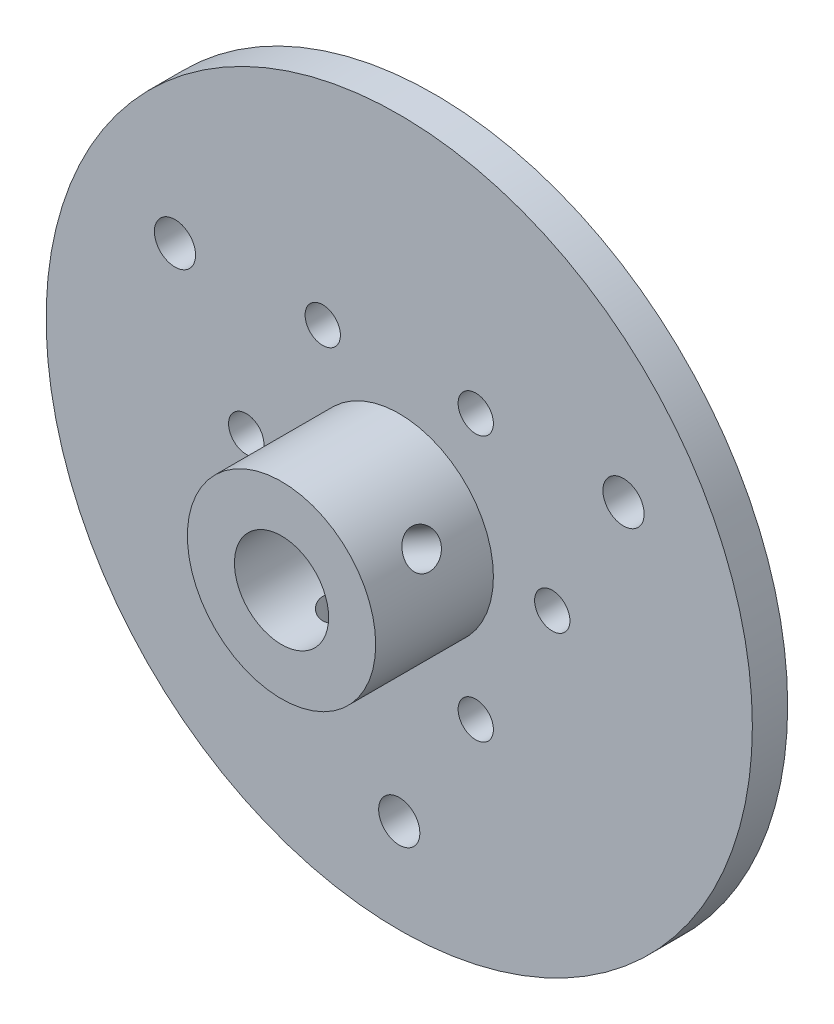
from build123d import *

# Parameters (mm, degrees)
SKETCH2_R           = 30
SKETCH2_R_2         = 4
SKETCH2_R_3         = 1.75
BOSS_EXTRUDE1_DEPTH = 3
SKETCH3_R           = 8
SKETCH3_R_2         = 4
BOSS_EXTRUDE2_DEPTH = 10
SKETCH4_R           = 1.5
CUT_EXTRUDE2_DEPTH  = 4
SKETCH12_R          = 1.5
CUT_EXTRUDE3_DEPTH  = 11.49377522
CIRPATTERN1_COUNT   = 3


with BuildPart() as part:
    # Sketch2 → Boss-Extrude1 (new body)
    with BuildSketch(Plane.XY):
        Circle(SKETCH2_R)
        Circle(SKETCH2_R_2, mode=Mode.SUBTRACT)
        with Locations((0, -22)):
            Circle(SKETCH2_R_3, mode=Mode.SUBTRACT)
        with Locations((-19.052558883, 11)):
            Circle(SKETCH2_R_3, mode=Mode.SUBTRACT)
        with Locations((19.052558883, 11)):
            Circle(SKETCH2_R_3, mode=Mode.SUBTRACT)
    extrude(amount=BOSS_EXTRUDE1_DEPTH)

    # Sketch3 → Boss-Extrude2 (add)
    with BuildSketch(Plane.XY.offset(3)):
        Circle(SKETCH3_R)
        Circle(SKETCH3_R_2, mode=Mode.SUBTRACT)
    extrude(amount=BOSS_EXTRUDE2_DEPTH)

    # Sketch4 → Cut-Extrude2 (cut, through all)
    with BuildSketch(Plane.XY.offset(3)):
        with Locations((-6.5, 11.258330249)):
            Circle(SKETCH4_R)
        with Locations((13, 0)):
            Circle(SKETCH4_R)
        with Locations((-6.5, -11.258330249)):
            Circle(SKETCH4_R)
        with Locations((6.5, 11.258330249)):
            Circle(SKETCH4_R)
        with Locations((6.5, -11.258330249)):
            Circle(SKETCH4_R)
        with Locations((-13, 0)):
            Circle(SKETCH4_R)
    extrude(amount=-CUT_EXTRUDE2_DEPTH, mode=Mode.SUBTRACT)

    # Sketch12 → Cut-Extrude3 (cut)
    with BuildSketch(Plane(origin=(0, 0, 0), x_dir=(1, 0, 0), z_dir=(0, 1, 0))):
        with Locations((0, -8)):
            Circle(SKETCH12_R)
    cut_extrude3 = extrude(amount=-CUT_EXTRUDE3_DEPTH, mode=Mode.SUBTRACT)

    # CirPattern1: Cut-Extrude3 ×3 about axis
    cirpattern1_axis = Axis((0, 0, 0), (0, 0, -1))
    for i in range(1, CIRPATTERN1_COUNT):
        add(cut_extrude3.rotate(cirpattern1_axis, i * 360 / CIRPATTERN1_COUNT), mode=Mode.SUBTRACT)


solid = part.part
